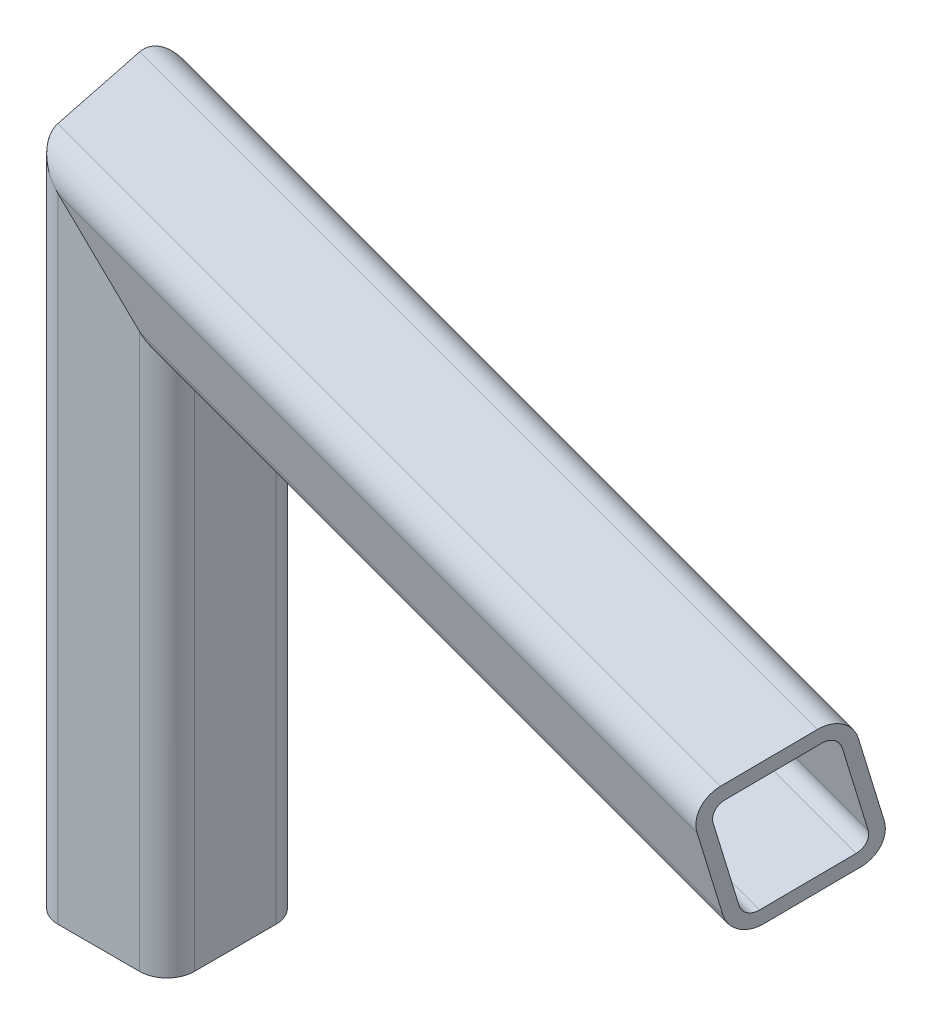
from build123d import *

# Parameters (mm, degrees)
QUADRATISCHES_HOHLPROFIL_20_X_20_X_2_24_DEPTH = 104.803576768
QUADRATISCHES_HOHLPROFIL_20_X_20_X_2_3_DEPTH  = 144.551658175


with BuildPart() as part:
    # Sketch1 → Quadratisches hohlprofil 20 X 20 X 2(24) (new body)
    with BuildSketch(Plane(origin=(0, 0, 0), x_dir=(1, 0, 0), z_dir=(0, 1, 0))):
        with BuildLine():
            Line((-6, -10), (6, -10))
            ThreePointArc((6, -10), (8.828427125, -8.828427125), (10, -6))
            Line((10, -6), (10, 6))
            ThreePointArc((10, 6), (8.828427125, 8.828427125), (6, 10))
            Line((6, 10), (-6, 10))
            ThreePointArc((-6, 10), (-8.828427125, 8.828427125), (-10, 6))
            Line((-10, 6), (-10, -6))
            ThreePointArc((-10, -6), (-8.828427125, -8.828427125), (-6, -10))
        make_face()
        with BuildLine():
            Line((-6, -8), (6, -8))
            ThreePointArc((6, -8), (7.414213562, -7.414213562), (8, -6))
            Line((8, -6), (8, 6))
            ThreePointArc((8, 6), (7.414213562, 7.414213562), (6, 8))
            Line((6, 8), (-6, 8))
            ThreePointArc((-6, 8), (-7.414213562, 7.414213562), (-8, 6))
            Line((-8, 6), (-8, -6))
            ThreePointArc((-8, -6), (-7.414213562, -7.414213562), (-6, -8))
        make_face(mode=Mode.SUBTRACT)
    extrude(amount=QUADRATISCHES_HOHLPROFIL_20_X_20_X_2_24_DEPTH)

    # Quadratisches hohlprofil 20 X 20 X 2 2
    split(bisect_by=Plane(origin=(0, 89.661441144, 0), x_dir=(0.719254597, -0.694746591, 0), z_dir=(-0.683012702, -0.707106781, -0.183012702)), keep=Keep.TOP)


with BuildPart() as body_2:
    # Sketch1 on segment 2 (carried to segment 2) → Quadratisches hohlprofil 20 X 20 X 2 3 (new body)
    with BuildSketch(Plane(origin=(-14.626179864, 89.661441144, -3.919073083), x_dir=(0.066987298, -0.965925826, -0.25), z_dir=(0.965925826, 0, 0.258819045))):
        with BuildLine():
            Line((-6, -10), (6, -10))
            ThreePointArc((6, -10), (8.828427125, -8.828427125), (10, -6))
            Line((10, -6), (10, 6))
            ThreePointArc((10, 6), (8.828427125, 8.828427125), (6, 10))
            Line((6, 10), (-6, 10))
            ThreePointArc((-6, 10), (-8.828427125, 8.828427125), (-10, 6))
            Line((-10, 6), (-10, -6))
            ThreePointArc((-10, -6), (-8.828427125, -8.828427125), (-6, -10))
        make_face()
        with BuildLine():
            Line((-6, -8), (6, -8))
            ThreePointArc((6, -8), (7.414213562, -7.414213562), (8, -6))
            Line((8, -6), (8, 6))
            ThreePointArc((8, 6), (7.414213562, 7.414213562), (6, 8))
            Line((6, 8), (-6, 8))
            ThreePointArc((-6, 8), (-7.414213562, 7.414213562), (-8, 6))
            Line((-8, 6), (-8, -6))
            ThreePointArc((-8, -6), (-7.414213562, -7.414213562), (-6, -8))
        make_face(mode=Mode.SUBTRACT)
    extrude(amount=QUADRATISCHES_HOHLPROFIL_20_X_20_X_2_3_DEPTH)

    # Quadratisches hohlprofil 20 X 20 X 2 3 m
    split(bisect_by=Plane(origin=(0, 89.661441144, 0), x_dir=(-0.719254597, 0.694746591, 0), z_dir=(0.683012702, 0.707106781, 0.183012702)), keep=Keep.TOP)


solid = Compound([part.part, body_2.part])
